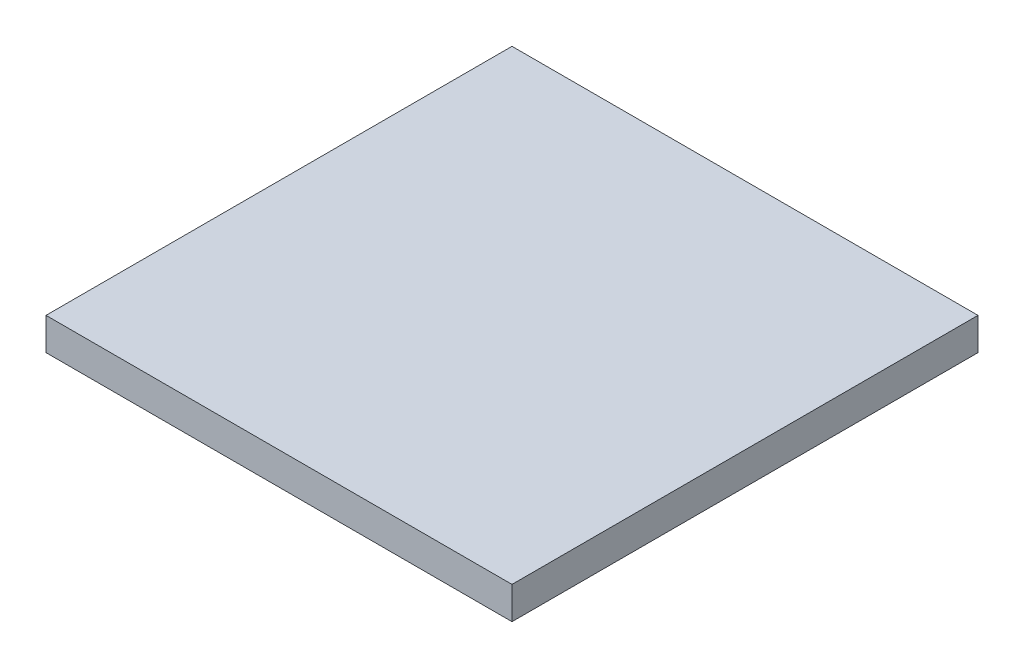
from build123d import *

# Parameters (mm, degrees)
SKETCH_1_W      = 30
SKETCH_1_H      = 30
EXTRUDE_1_DEPTH = 2.08


with BuildPart() as part:
    # 草图1 → 凸台-拉伸1 (new body)
    with BuildSketch(Plane(origin=(0, 0, 0), x_dir=(1, 0, 0), z_dir=(0, 1, 0))):
        Rectangle(SKETCH_1_W, SKETCH_1_H)
    extrude(amount=EXTRUDE_1_DEPTH)


solid = part.part
